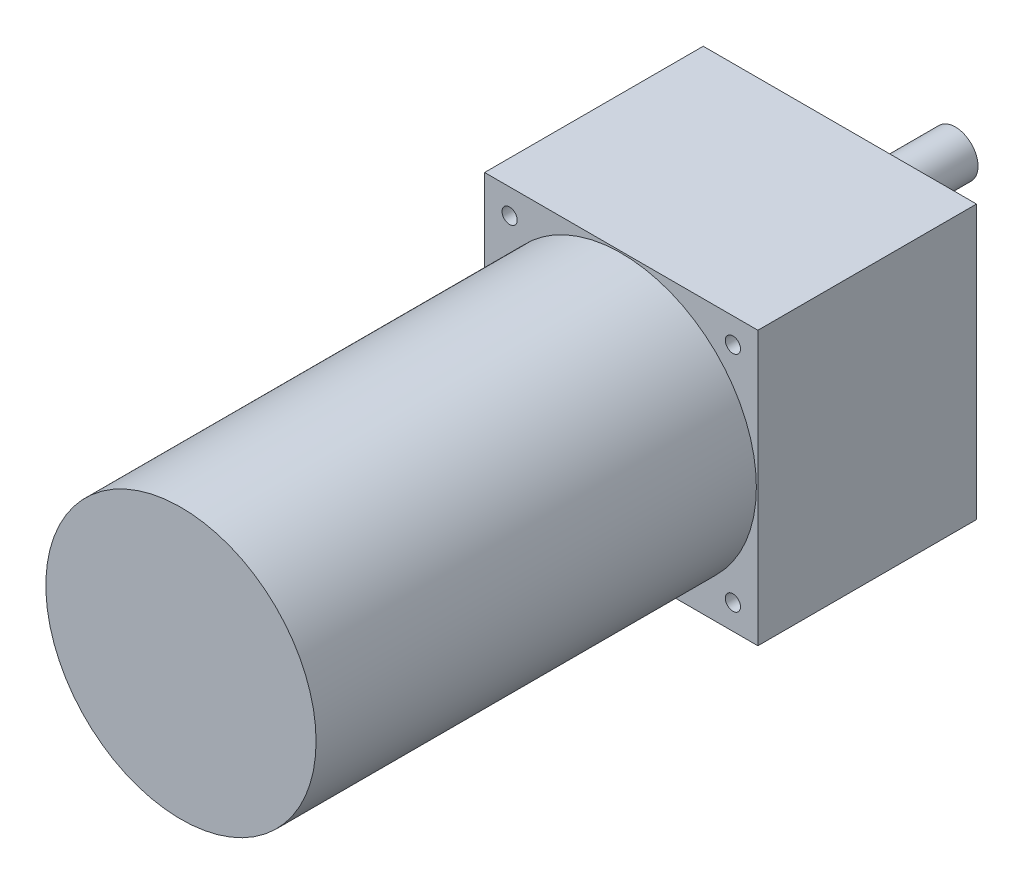
from build123d import *

# Parameters (mm, degrees)
SKETCH_2_W         = 90
SKETCH_2_H         = 90
EXTRUDE_1_DEPTH    = 7
SKETCH_3_R         = 44.5
EXTRUDE_2_DEPTH    = 145
SKETCH_4_W         = 90
SKETCH_4_H         = 90
EXTRUDE_3_DEPTH    = 65
SKETCH_6_R         = 7.5
EXTRUDE_4_DEPTH    = 38
HOLE_WIZARD_M6_1_D = 5


with BuildPart() as part:
    # 草图2 → 凸台-拉伸1 (new body)
    with BuildSketch(Plane.XY):
        Rectangle(SKETCH_2_W, SKETCH_2_H)
    extrude(amount=EXTRUDE_1_DEPTH)

    # 草图3 → 凸台-拉伸2 (add)
    with BuildSketch(Plane.XY.offset(7)):
        Circle(SKETCH_3_R)
    extrude(amount=EXTRUDE_2_DEPTH)

    # 草图4 → 凸台-拉伸3 (add)
    with BuildSketch(Plane(origin=(0, 0, 0), x_dir=(-1, 0, 0), z_dir=(0, 0, -1))):
        Rectangle(SKETCH_4_W, SKETCH_4_H)
    extrude(amount=EXTRUDE_3_DEPTH)

    # 草图6 → 凸台-拉伸4 (add)
    with BuildSketch(Plane(origin=(0, 0, -65), x_dir=(-1, 0, 0), z_dir=(0, 0, -1))):
        with Locations((0, 18)):
            Circle(SKETCH_6_R)
    extrude(amount=EXTRUDE_4_DEPTH)

    # M6 螺纹孔1 (through all)
    with Locations(Plane(origin=(36.769552622, 36.769552622, -65), x_dir=(-1, 0, 0), z_dir=(0, 0, -1))):
        with Locations((0, 0), (73.539105244, 0), (73.539105244, -73.539105244), (0, -73.539105244)):
            Hole(HOLE_WIZARD_M6_1_D / 2)


solid = part.part
